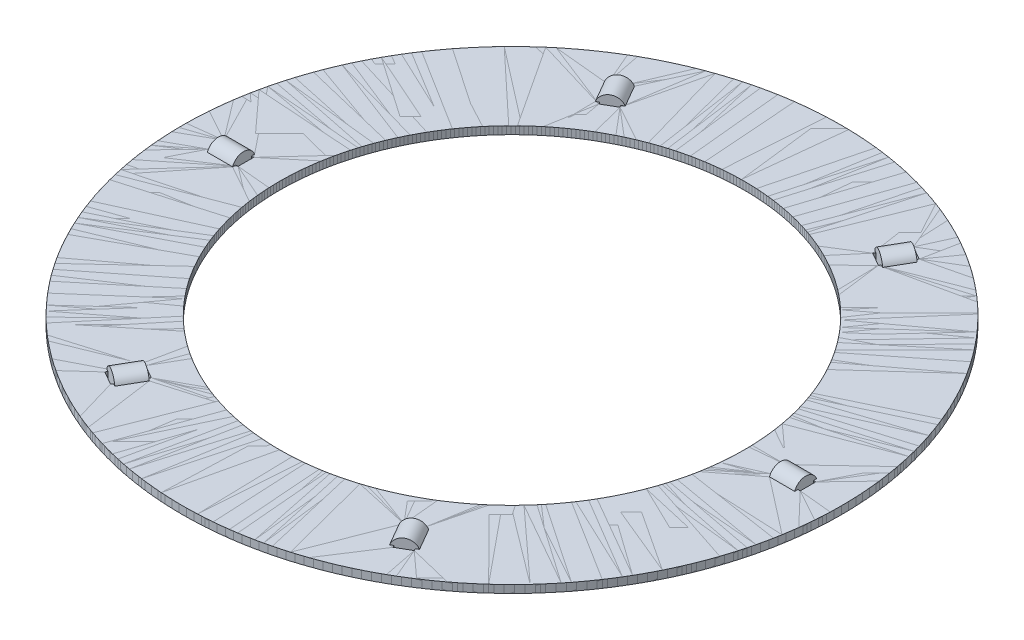
from build123d import *

# Parameters (mm, degrees)
SKETCH_2_W               = 12.5
SKETCH_2_H               = 1
SKETCH_3_W               = 3.85
SKETCH_3_H               = 3
CUT_EXTRUDE_2_DEPTH      = 1
PATTERN_CIRCULAR_1_COUNT = 6
SKETCH_2_6_W             = 3.25
SKETCH_2_6_H             = 1
SKETCH_2_6_H_2           = 0.5
PATTERN_CIRCULAR_2_COUNT = 6


with BuildPart() as part:
    # Sketch 2 → Revolve 1 (revolve)
    with BuildSketch(Plane.XY):
        with Locations((-36.25, 0)):
            Rectangle(SKETCH_2_W, SKETCH_2_H)
    revolve(axis=Axis((0, 87.206131479, 0), (0, -1, 0)))

    # Sketch 3 → Cut-Extrude 2 (cut, symmetric)
    with BuildSketch(Plane.XY):
        with Locations((-36.25, 0)):
            Rectangle(SKETCH_3_W, SKETCH_3_H)
    cut_extrude_2 = extrude(amount=CUT_EXTRUDE_2_DEPTH, both=True, mode=Mode.SUBTRACT)

    # Pattern Circular 1: Cut-Extrude 2 ×6 about axis
    pattern_circular_1_axis = Axis((0, 0, 0), (0, 1, 0))
    for i in range(1, PATTERN_CIRCULAR_1_COUNT):
        add(cut_extrude_2.rotate(pattern_circular_1_axis, i * 360 / PATTERN_CIRCULAR_1_COUNT), mode=Mode.SUBTRACT)

    # Sketch 2_6 → Revolve 5 (revolve)
    with BuildSketch(Plane.XY):
        with Locations((-36.25, 1)):
            Rectangle(SKETCH_2_6_W, SKETCH_2_6_H)
        with Locations((-36.25, 0.25)):
            Rectangle(SKETCH_2_6_W, SKETCH_2_6_H_2)
    revolve(axis=Axis((-94.332720146, 0, 0), (1, 0, 0)))


with BuildPart() as pattern_circular_2_1:
    # Pattern Circular 2: pattern copy
    add(part.part.rotate(Axis((0, 0, 0), (0, 1, 0)), 1 * 360 / PATTERN_CIRCULAR_2_COUNT))


with BuildPart() as pattern_circular_2_2:
    # Pattern Circular 2: pattern copy
    add(part.part.rotate(Axis((0, 0, 0), (0, 1, 0)), 2 * 360 / PATTERN_CIRCULAR_2_COUNT))


with BuildPart() as pattern_circular_2_3:
    # Pattern Circular 2: pattern copy
    add(part.part.rotate(Axis((0, 0, 0), (0, 1, 0)), 3 * 360 / PATTERN_CIRCULAR_2_COUNT))


with BuildPart() as pattern_circular_2_4:
    # Pattern Circular 2: pattern copy
    add(part.part.rotate(Axis((0, 0, 0), (0, 1, 0)), 4 * 360 / PATTERN_CIRCULAR_2_COUNT))


with BuildPart() as pattern_circular_2_5:
    # Pattern Circular 2: pattern copy
    add(part.part.rotate(Axis((0, 0, 0), (0, 1, 0)), 5 * 360 / PATTERN_CIRCULAR_2_COUNT))


solid = Compound([part.part, pattern_circular_2_1.part, pattern_circular_2_2.part, pattern_circular_2_3.part, pattern_circular_2_4.part, pattern_circular_2_5.part])
